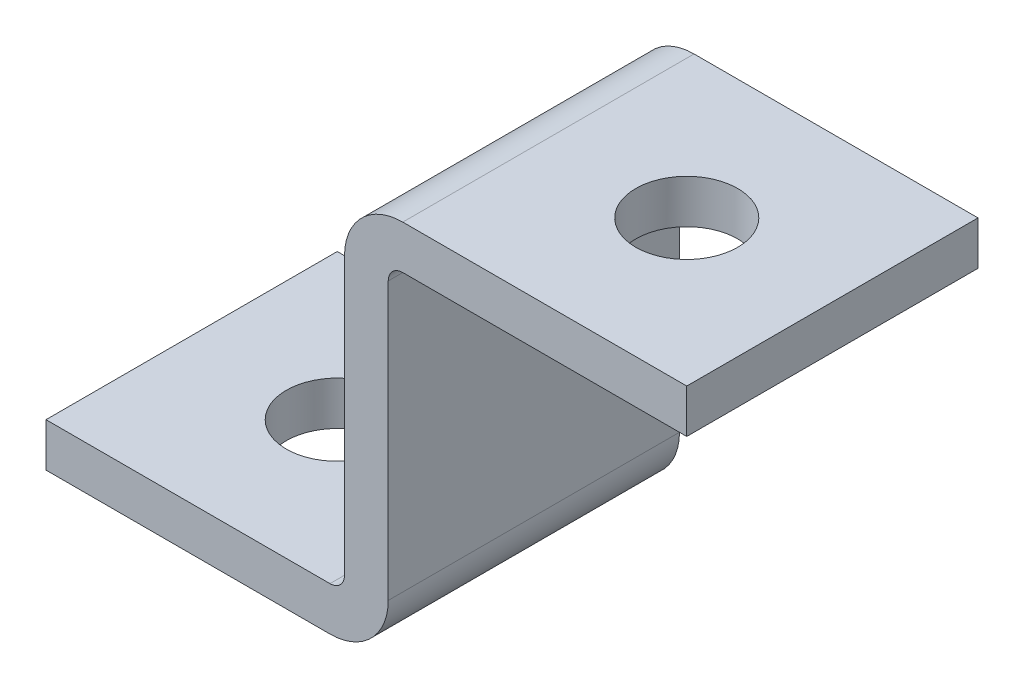
from build123d import *

# Parameters (mm, degrees)
SKETCH1_W                      = 88
SKETCH1_H                      = 54
BOSS_EXTRUDE1_DEPTH            = 40
SKETCH2_W                      = 41
SKETCH2_H                      = 48
CUT_EXTRUDE1_DEPTH             = 41
SKETCH3_W                      = 41
SKETCH3_H                      = 48
CUT_EXTRUDE2_DEPTH             = 41
F_14_0_14_DIAMETER_HOLE1_D     = 14
F_14_0_14_DIAMETER_HOLE1_DEPTH = 54
F_14_0_14_DIAMETER_HOLE2_D     = 14
F_14_0_14_DIAMETER_HOLE2_DEPTH = 54
FILLET1_R                      = 2
FILLET2_R                      = 8


with BuildPart() as part:
    # Sketch1 → Boss-Extrude1 (new body)
    with BuildSketch(Plane(origin=(0, 0, -40), x_dir=(-1, 0, 0), z_dir=(0, 0, -1))):
        with Locations((-44, 27)):
            Rectangle(SKETCH1_W, SKETCH1_H)
    extrude(amount=-BOSS_EXTRUDE1_DEPTH)

    # Sketch2 → Cut-Extrude1 (cut, through all)
    with BuildSketch(Plane.XY):
        with Locations((20.5, 30)):
            Rectangle(SKETCH2_W, SKETCH2_H)
    extrude(amount=-CUT_EXTRUDE1_DEPTH, mode=Mode.SUBTRACT)

    # Sketch3 → Cut-Extrude2 (cut, through all)
    with BuildSketch(Plane.XY):
        with Locations((67.5, 24)):
            Rectangle(SKETCH3_W, SKETCH3_H)
    extrude(amount=-CUT_EXTRUDE2_DEPTH, mode=Mode.SUBTRACT)

    # Ø14.0 (14) Diameter Hole1
    with Locations(Plane(origin=(0, 0, 0), x_dir=(-1, 0, 0), z_dir=(0, -1, 0))):
        with Locations((-20, 20)):
            Hole(F_14_0_14_DIAMETER_HOLE1_D / 2, depth=F_14_0_14_DIAMETER_HOLE1_DEPTH)

    # Ø14.0 (14) Diameter Hole2
    with Locations(Plane(origin=(0, 54, 0), x_dir=(1, 0, 0), z_dir=(0, 1, 0))):
        with Locations((68, 20)):
            Hole(F_14_0_14_DIAMETER_HOLE2_D / 2, depth=F_14_0_14_DIAMETER_HOLE2_DEPTH)

    # Fillet1
    fillet1_edges = [part.edges().sort_by_distance(p)[0] for p in [
        (41, 6, -20),
        (47, 48, -20),
    ]]
    fillet(fillet1_edges, radius=FILLET1_R)

    # Fillet2
    fillet2_edges = [part.edges().sort_by_distance(p)[0] for p in [
        (41, 54, -20),
        (47, 0, -20),
    ]]
    fillet(fillet2_edges, radius=FILLET2_R)


solid = part.part
